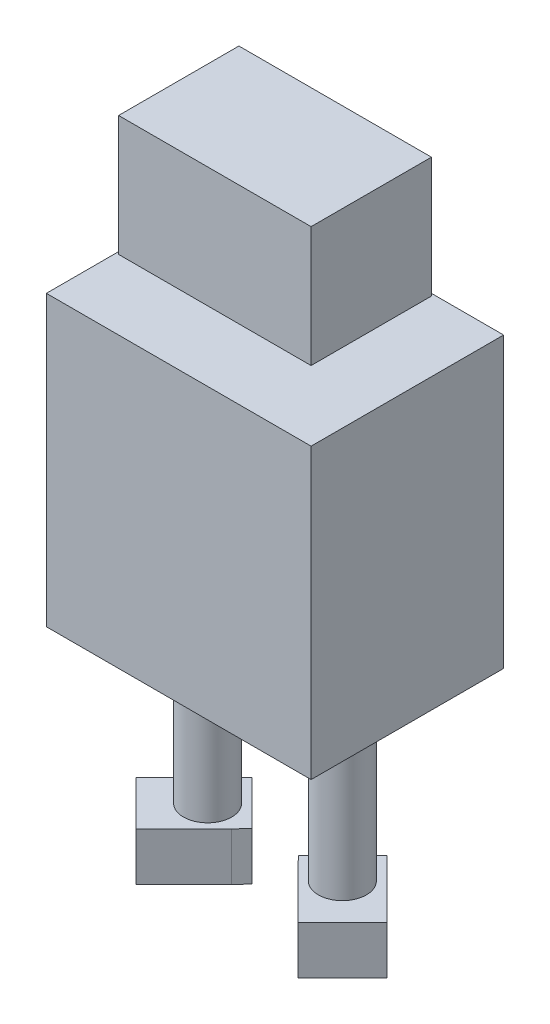
from build123d import *

# Parameters (mm, degrees)
SKETCH1_W           = 55
SKETCH1_H           = 60
BOSS_EXTRUDE1_DEPTH = 40
SKETCH2_R           = 4
BOSS_EXTRUDE2_DEPTH = 7
SKETCH4_W           = 40
SKETCH4_H           = 25
BOSS_EXTRUDE3_DEPTH = 25
SKETCH5_R           = 5
BOSS_EXTRUDE4_DEPTH = 35
BOSS_EXTRUDE5_DEPTH = 10


with BuildPart() as part:
    # Sketch1 → Boss-Extrude1 (new body)
    with BuildSketch(Plane.XY):
        Rectangle(SKETCH1_W, SKETCH1_H)
    extrude(amount=BOSS_EXTRUDE1_DEPTH)

    # Sketch2 → Boss-Extrude2 (add)
    with BuildSketch(Plane(origin=(0, 30, 0), x_dir=(-1, 0, 0), z_dir=(0, 1, 0))):
        with Locations((0, 20)):
            Circle(SKETCH2_R)
    extrude(amount=BOSS_EXTRUDE2_DEPTH)

    # Sketch4 → Boss-Extrude3 (add)
    with BuildSketch(Plane(origin=(0, 37, 0), x_dir=(1, 0, 0), z_dir=(0, 1, 0))):
        with Locations((0, -20)):
            Rectangle(SKETCH4_W, SKETCH4_H)
    extrude(amount=BOSS_EXTRUDE3_DEPTH)

    # Sketch5 → Boss-Extrude4 (add)
    with BuildSketch(Plane.XZ.offset(30)):
        with Locations((-14, 20)):
            Circle(SKETCH5_R)
        with Locations((14, 20)):
            Circle(SKETCH5_R)
    extrude(amount=BOSS_EXTRUDE4_DEPTH)

    # Sketch6 → Boss-Extrude5 (add)
    with BuildSketch(Plane.XZ.offset(65)):
        Polygon((-11.888014897, 12.878679656), (-6.888014897, 17.878679656), (-4.829546686, 19.937147868), (-6.888014897, 22.121320344), (-11.888014897, 27.121320344), (-16.837762365, 32.071067812), (-18.959082709, 29.949747468), (-23.959082709, 24.949747468), (-26.080403052, 22.828427125), (-21.130655584, 17.878679656), (-16.130655584, 12.878679656), (-14.009335241, 10.757359313), align=None)
        Polygon((18.949747468, 29.949747468), (23.949747468, 24.949747468), (26.071067812, 22.828427125), (21.121320344, 17.878679656), (16.121320344, 12.878679656), (14, 10.757359313), (11.878679656, 12.878679656), (6.878679656, 17.878679656), (4.820211445, 19.937147868), (6.878679656, 22.121320344), (11.878679656, 27.121320344), (16.828427125, 32.071067812), align=None)
    extrude(amount=BOSS_EXTRUDE5_DEPTH)


solid = part.part
